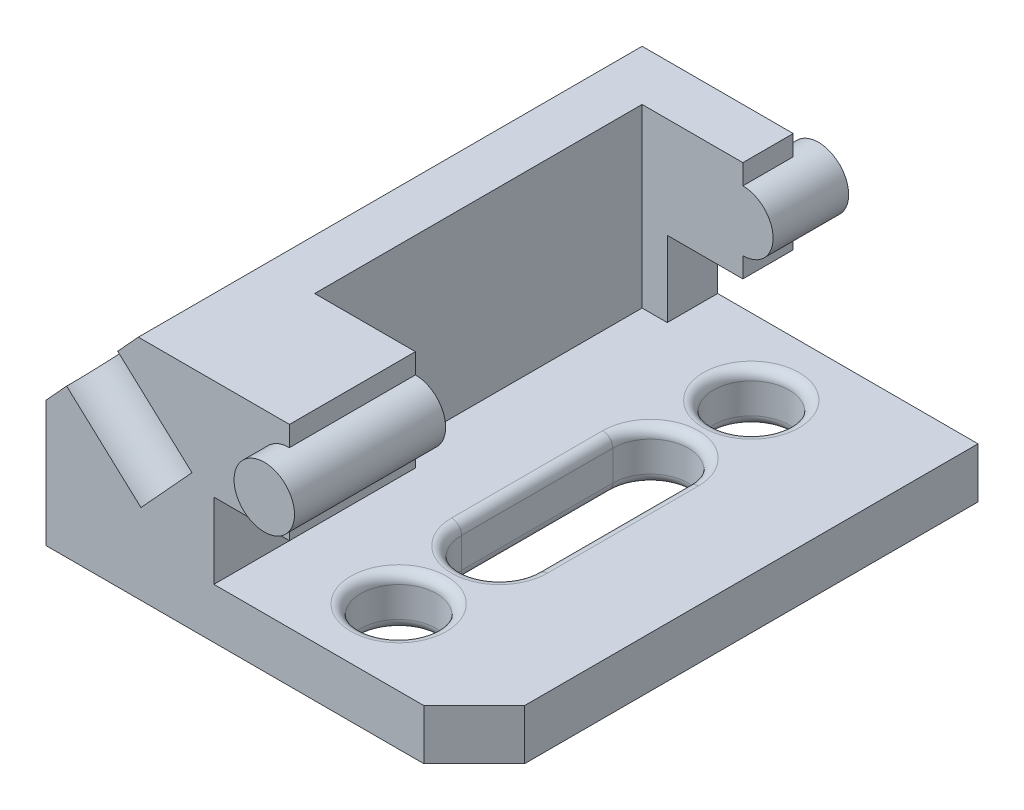
from build123d import *

# Parameters (mm, degrees)
SKETCH1_R           = 6
BOSS_EXTRUDE1_DEPTH = 100
SKETCH3_R           = 6
BOSS_EXTRUDE2_DEPTH = 5
SKETCH4_R           = 6
BOSS_EXTRUDE3_DEPTH = 5
SKETCH5_R           = 7.5
CUT_EXTRUDE1_DEPTH  = 20
CUT_EXTRUDE2_DEPTH  = 35
SKETCH8_R           = 7.5
CUT_EXTRUDE3_DEPTH  = 10
CUT_EXTRUDE4_DEPTH  = 10
FILLET1_R           = 2


with BuildPart() as part:
    # Sketch1 → Boss-Extrude1 (new body)
    with BuildSketch(Plane.XY):
        with Locations((48.32662348, 35)):
            Circle(SKETCH1_R)
        Polygon((48.32662348, 25), (48.32662348, 45), (18.32662348, 45), (0, 25), (0, 0), (85, 0), (85, 10), (33.32662348, 10), (33.32662348, 25), align=None)
        with BuildLine():
            ThreePointArc((54.32662348, 35), (52.569264167, 39.242640687), (48.32662348, 41))
            Line((48.32662348, 41), (48.32662348, 29))
            ThreePointArc((48.32662348, 29), (52.569264167, 30.757359313), (54.32662348, 35))
        make_face()
        with BuildLine():
            Line((48.32662348, 29), (48.32662348, 41))
            ThreePointArc((48.32662348, 41), (42.32662348, 35), (48.32662348, 29))
        make_face()
    extrude(amount=BOSS_EXTRUDE1_DEPTH)

    # Sketch3 → Boss-Extrude2 (add)
    with BuildSketch(Plane.XY.offset(100)):
        with Locations((48.32662348, 35)):
            Circle(SKETCH3_R)
    extrude(amount=BOSS_EXTRUDE2_DEPTH)

    # Sketch4 → Boss-Extrude3 (add)
    with BuildSketch(Plane(origin=(0, 0, 0), x_dir=(-1, 0, 0), z_dir=(0, 0, -1))):
        with Locations((-48.32662348, 35)):
            Circle(SKETCH4_R)
    extrude(amount=BOSS_EXTRUDE3_DEPTH)

    # Sketch5 → Cut-Extrude1 (cut)
    with BuildSketch(Plane(origin=(-12.452433726, 11.410553216, 0), x_dir=(0.675590208, 0.737277337, 0), z_dir=(-0.737277337, 0.675590208, 0))):
        with Locations((31.995350469, -100)):
            Circle(SKETCH5_R)
    extrude(amount=-CUT_EXTRUDE1_DEPTH, mode=Mode.SUBTRACT)

    # Sketch6 → Cut-Extrude2 (cut)
    with BuildSketch(Plane(origin=(0, 45, 0), x_dir=(1, 0, 0), z_dir=(0, 1, 0))):
        Polygon((48.32662348, -10), (28.32662348, -10), (28.32662348, -75), (54.32662348, -75), (54.32662348, -10), align=None)
    extrude(amount=-CUT_EXTRUDE2_DEPTH, mode=Mode.SUBTRACT)

    # Sketch8 → Cut-Extrude3 (cut)
    with BuildSketch(Plane(origin=(0, 10, 0), x_dir=(1, 0, 0), z_dir=(0, 1, 0))):
        with Locations((55, -15)):
            Circle(SKETCH8_R)
        with Locations((55, -85)):
            Circle(SKETCH8_R)
        with BuildLine():
            Line((47.5, -65), (47.5, -35))
            ThreePointArc((47.5, -35), (55, -27.5), (62.5, -35))
            Line((62.5, -35), (62.5, -65))
            ThreePointArc((62.5, -65), (55, -72.5), (47.5, -65))
        make_face()
    extrude(amount=-CUT_EXTRUDE3_DEPTH, mode=Mode.SUBTRACT)

    # Sketch9 → Cut-Extrude4 (cut)
    with BuildSketch(Plane(origin=(0, 10, 0), x_dir=(1, 0, 0), z_dir=(0, 1, 0))):
        Polygon((75, -100), (85, -90), (85, -100), align=None)
    extrude(amount=-CUT_EXTRUDE4_DEPTH, mode=Mode.SUBTRACT)

    # Fillet1
    fillet1_edges = [part.edges().sort_by_distance(p)[0] for p in [
        (47.5, 10, 15),
        (47.5, 0, 15),
        (55, 10, 27.5),
        (47.5, 10, 50),
        (55, 10, 72.5),
        (62.5, 10, 50),
        (55, 0, 27.5),
        (62.5, 0, 50),
        (55, 0, 72.5),
        (47.5, 0, 50),
        (47.5, 10, 85),
        (47.5, 0, 85),
    ]]
    fillet(fillet1_edges, radius=FILLET1_R)


solid = part.part
